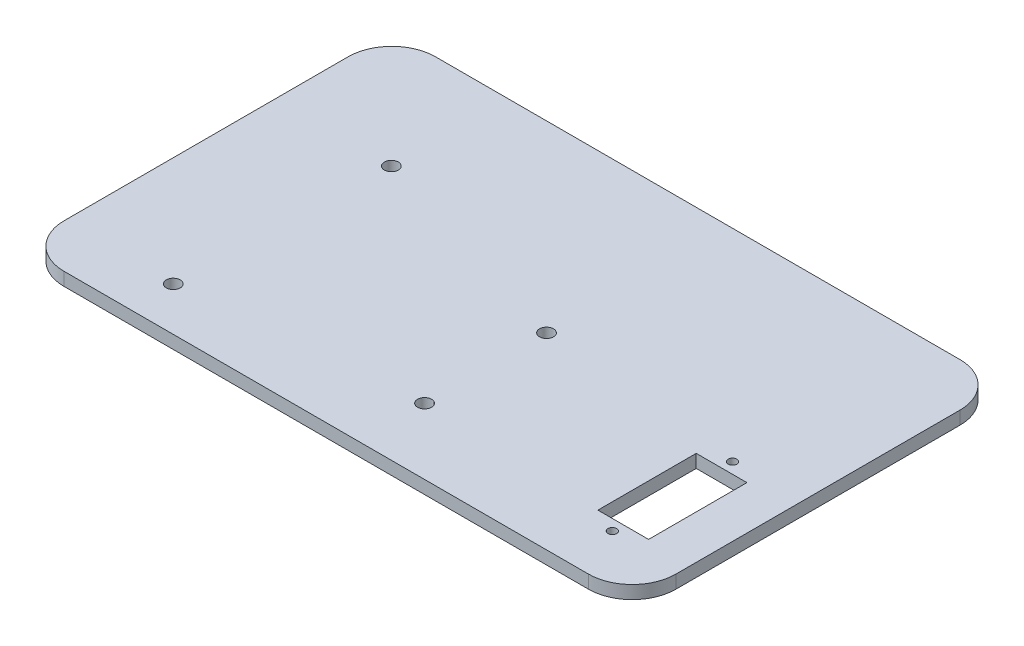
from build123d import *

# Parameters (mm, degrees)
SKETCH3_W           = 140
SKETCH3_H           = 85
BOSS_EXTRUDE1_DEPTH = 3
SKETCH4_R           = 1.6
CUT_EXTRUDE1_DEPTH  = 3
FILLET1_R           = 10
FILLET2_R           = 10
FILLET3_R           = 10
FILLET4_R           = 10
SKETCH7_R           = 1
SKETCH7_W           = 11.6
SKETCH7_H           = 22.5
CUT_EXTRUDE4_DEPTH  = 3


with BuildPart() as part:
    # Sketch3 → Boss-Extrude1 (new body)
    with BuildSketch(Plane(origin=(0, 0, 0), x_dir=(1, 0, 0), z_dir=(0, 1, 0))):
        Rectangle(SKETCH3_W, SKETCH3_H)
    extrude(amount=BOSS_EXTRUDE1_DEPTH)

    # Sketch4 → Cut-Extrude1 (cut)
    with BuildSketch(Plane(origin=(0, 3, 0), x_dir=(1, 0, 0), z_dir=(0, 1, 0))):
        with Locations((-43.4, 15.8)):
            Circle(SKETCH4_R)
        with Locations((7.4, 0.5)):
            Circle(SKETCH4_R)
        with Locations((-45, -32.5)):
            Circle(SKETCH4_R)
        with Locations((7.4, -27.4)):
            Circle(SKETCH4_R)
    extrude(amount=-CUT_EXTRUDE1_DEPTH, mode=Mode.SUBTRACT)

    # Fillet1
    fillet1_edges = [part.edges().sort_by_distance(p)[0] for p in [
        (-70, 1.5, 42.5),
    ]]
    fillet(fillet1_edges, radius=FILLET1_R)

    # Fillet2
    fillet2_edges = [part.edges().sort_by_distance(p)[0] for p in [
        (-70, 1.5, -42.5),
    ]]
    fillet(fillet2_edges, radius=FILLET2_R)

    # Fillet3
    fillet3_edges = [part.edges().sort_by_distance(p)[0] for p in [
        (70, 1.5, -42.5),
    ]]
    fillet(fillet3_edges, radius=FILLET3_R)

    # Fillet4
    fillet4_edges = [part.edges().sort_by_distance(p)[0] for p in [
        (70, 1.5, 42.5),
    ]]
    fillet(fillet4_edges, radius=FILLET4_R)

    # Sketch7 → Cut-Extrude4 (cut)
    with BuildSketch(Plane(origin=(0, 3, 0), x_dir=(1, 0, 0), z_dir=(0, 1, 0))):
        with Locations((54.2, -31.25)):
            Circle(SKETCH7_R)
        with Locations((54.2, -3.75)):
            Circle(SKETCH7_R)
        with Locations((54.2, -17.5)):
            Rectangle(SKETCH7_W, SKETCH7_H)
    extrude(amount=-CUT_EXTRUDE4_DEPTH, mode=Mode.SUBTRACT)


solid = part.part
